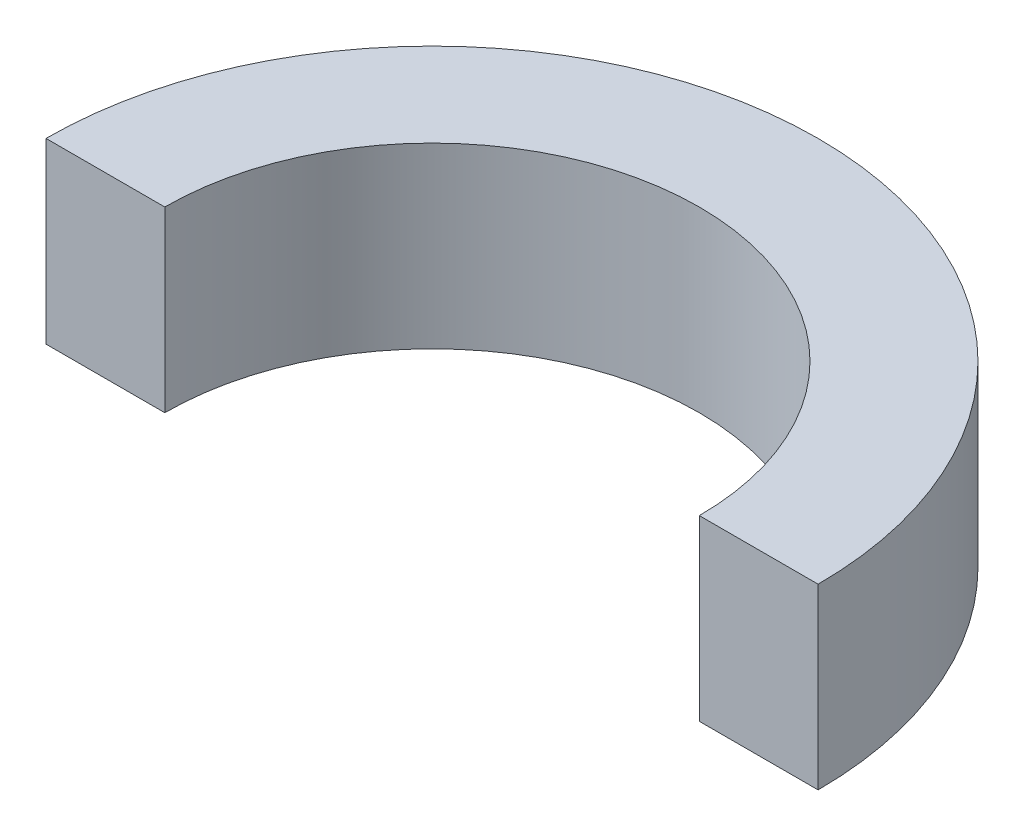
from build123d import *

# Parameters (mm, degrees)
BOSS_EXTRUDE1_DEPTH = 6


with BuildPart() as part:
    # Sketch1 → Boss-Extrude1 (new body)
    with BuildSketch(Plane(origin=(0, 0, 0), x_dir=(1, 0, 0), z_dir=(0, 1, 0))):
        with BuildLine():
            Line((-13, 0), (-9, 0))
            ThreePointArc((-9, 0), (0, 9), (9, 0))
            Line((9, 0), (13, 0))
            ThreePointArc((13, 0), (0, 13), (-13, 0))
        make_face()
    extrude(amount=BOSS_EXTRUDE1_DEPTH)


solid = part.part
